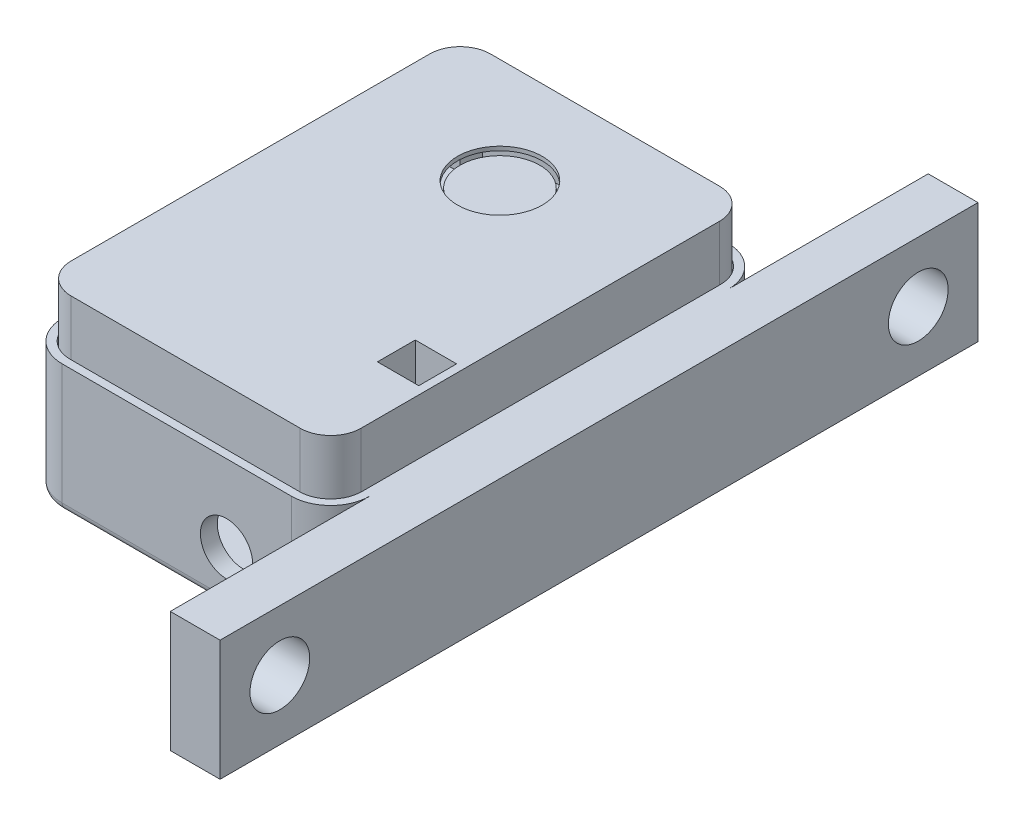
from build123d import *

# Parameters (mm, degrees)
BOSS_EXTRUDE1_DEPTH     = 1
SKETCH2_W               = 15
SKETCH2_H               = 15
BOSS_EXTRUDE2_DEPTH     = 2
SKETCH3_R               = 4
BOSS_EXTRUDE3_DEPTH     = 6.25
SKETCH5_W               = 3
SKETCH5_H               = 3
BOSS_EXTRUDE4_DEPTH     = 1
BOSS_EXTRUDE5_START     = 0.25
SKETCH6_R               = 4.25
BOSS_EXTRUDE5_DEPTH     = 0.4
BOSS_EXTRUDE7_DEPTH     = 9.5
BOSS_EXTRUDE9_DEPTH     = 8.4
SKETCH11_W              = 4.15
SKETCH11_H              = 3.8
CUT_EXTRUDE1_DEPTH      = 0.4
SKETCH12_W              = 18.75
SKETCH12_H              = 25.65
BOSS_EXTRUDE10_DEPTH    = 0.75
BOSS_EXTRUDE11_DEPTH    = 2.3
SKETCH14_W              = 2.5
SKETCH14_H              = 20.2
BOSS_EXTRUDE12_DEPTH    = 2.45
SKETCH16_W              = 0.6
SKETCH16_H              = 0.6
BOSS_EXTRUDE14_DEPTH    = 5.5
LPATTERN1_COUNT         = 8
LPATTERN1_PITCH         = 2.5
BOSS_EXTRUDE15_START    = 5
BOSS_EXTRUDE15_DEPTH    = 12.5
BOSS_EXTRUDE16_DEPTH    = 7.95
SKETCH19_W              = 3.5
SKETCH19_H              = 21.2
BOSS_EXTRUDE17_DEPTH    = 0.4
SKETCH20_R              = 2.625
CUT_EXTRUDE2_DEPTH      = 1.7
BOSS_EXTRUDE18_DEPTH    = 7.95
BOSS_EXTRUDE19_DEPTH    = 7.4
MIRROR1_COPY_1_SKETCH_W = 0.6
MIRROR1_COPY_1_SKETCH_H = 0.6
MIRROR1_COPY_1_DEPTH    = 5.5
MIRROR1_COPY_2_SKETCH_W = 0.6
MIRROR1_COPY_2_SKETCH_H = 0.6
MIRROR1_COPY_2_DEPTH    = 5.5
MIRROR1_COPY_3_SKETCH_W = 0.6
MIRROR1_COPY_3_SKETCH_H = 0.6
MIRROR1_COPY_3_DEPTH    = 5.5
MIRROR1_COPY_4_SKETCH_W = 0.6
MIRROR1_COPY_4_SKETCH_H = 0.6
MIRROR1_COPY_4_DEPTH    = 5.5
MIRROR1_COPY_5_SKETCH_W = 0.6
MIRROR1_COPY_5_SKETCH_H = 0.6
MIRROR1_COPY_5_DEPTH    = 5.5
MIRROR1_COPY_6_SKETCH_W = 0.6
MIRROR1_COPY_6_SKETCH_H = 0.6
MIRROR1_COPY_6_DEPTH    = 5.5
MIRROR1_COPY_7_SKETCH_W = 0.6
MIRROR1_COPY_7_SKETCH_H = 0.6
MIRROR1_COPY_7_DEPTH    = 5.5
FILLET2_R               = 0.8
SKETCH27_R              = 3
SKETCH27_W              = 36
SKETCH27_H              = 12.1
BOSS_EXTRUDE20_DEPTH    = 5


with BuildPart() as part:
    # Sketch1 → Boss-Extrude1 (new body)
    with BuildSketch(Plane(origin=(0, 0, 0), x_dir=(1, 0, 0), z_dir=(0, 1, 0))):
        with BuildLine():
            Line((-11.5, 20), (11.5, 20))
            ThreePointArc((11.5, 20), (12.914213562, 19.414213562), (13.5, 18))
            Line((13.5, 18), (13.5, -18))
            ThreePointArc((13.5, -18), (12.914213562, -19.414213562), (11.5, -20))
            Line((11.5, -20), (-11.5, -20))
            ThreePointArc((-11.5, -20), (-12.914213562, -19.414213562), (-13.5, -18))
            Line((-13.5, -18), (-13.5, 18))
            ThreePointArc((-13.5, 18), (-12.914213562, 19.414213562), (-11.5, 20))
        make_face()
    extrude(amount=BOSS_EXTRUDE1_DEPTH)

    # Sketch2 → Boss-Extrude2 (add)
    with BuildSketch(Plane(origin=(0, 1, 0), x_dir=(1, 0, 0), z_dir=(0, 1, 0))):
        with Locations((0, 12.5)):
            Rectangle(SKETCH2_W, SKETCH2_H)
    extrude(amount=BOSS_EXTRUDE2_DEPTH)

    # Sketch3 → Boss-Extrude3 (add)
    with BuildSketch(Plane(origin=(0, 3, 0), x_dir=(1, 0, 0), z_dir=(0, 1, 0))):
        with Locations((0, 10.5)):
            Circle(SKETCH3_R)
    extrude(amount=BOSS_EXTRUDE3_DEPTH)

    # Sketch5 → Boss-Extrude4 (add)
    with BuildSketch(Plane(origin=(0, 1, 0), x_dir=(1, 0, 0), z_dir=(0, 1, 0))):
        with Locations((11.5, -9.5)):
            Rectangle(SKETCH5_W, SKETCH5_H)
    extrude(amount=BOSS_EXTRUDE4_DEPTH)

    # Sketch12 → Boss-Extrude10 (add)
    with BuildSketch(Plane.XZ):
        with Locations((0, 7.175)):
            Rectangle(SKETCH12_W, SKETCH12_H)
    extrude(amount=BOSS_EXTRUDE10_DEPTH)

    # Sketch13 → Boss-Extrude11 (add)
    with BuildSketch(Plane.XZ.offset(0.75)):
        Polygon((2, 12.35), (-8, 12.35), (-8, -5.15), (8, -5.15), (8, 9.35), (2, 9.35), align=None)
    extrude(amount=BOSS_EXTRUDE11_DEPTH)

    # Sketch14 → Boss-Extrude12 (add)
    with BuildSketch(Plane.XZ):
        with Locations((11.5, -6.1)):
            Rectangle(SKETCH14_W, SKETCH14_H)
    boss_extrude12 = extrude(amount=BOSS_EXTRUDE12_DEPTH)

    # Sketch16 → Boss-Extrude14 (add)
    with BuildSketch(Plane.XZ.offset(2.45)):
        with Locations((11.5, 2.7)):
            Rectangle(SKETCH16_W, SKETCH16_H)
    boss_extrude14 = extrude(amount=BOSS_EXTRUDE14_DEPTH)

    # LPattern1: Boss-Extrude14 ×8
    with Locations(*[(0, 0, -i * LPATTERN1_PITCH) for i in range(1, LPATTERN1_COUNT)]):
        add(boss_extrude14)

    # Mirror1: Boss-Extrude12, Boss-Extrude14 across plane
    add(boss_extrude12.mirror(Plane(origin=(0, 0, 0), x_dir=(0, 0, 1), z_dir=(1, 0, 0))))
    add(boss_extrude14.mirror(Plane(origin=(0, 0, 0), x_dir=(0, 0, 1), z_dir=(1, 0, 0))))

    # Mirror1 copy 1 sketch → Mirror1 copy 1 (add)
    with BuildSketch(Plane(origin=(0, -2.45, -2.5), x_dir=(-1, 0, 0), z_dir=(0, -1, 0))):
        with Locations((11.5, -2.7)):
            Rectangle(MIRROR1_COPY_1_SKETCH_W, MIRROR1_COPY_1_SKETCH_H)
    extrude(amount=MIRROR1_COPY_1_DEPTH)

    # Mirror1 copy 2 sketch → Mirror1 copy 2 (add)
    with BuildSketch(Plane(origin=(0, -2.45, -5), x_dir=(-1, 0, 0), z_dir=(0, -1, 0))):
        with Locations((11.5, -2.7)):
            Rectangle(MIRROR1_COPY_2_SKETCH_W, MIRROR1_COPY_2_SKETCH_H)
    extrude(amount=MIRROR1_COPY_2_DEPTH)

    # Mirror1 copy 3 sketch → Mirror1 copy 3 (add)
    with BuildSketch(Plane(origin=(0, -2.45, -7.5), x_dir=(-1, 0, 0), z_dir=(0, -1, 0))):
        with Locations((11.5, -2.7)):
            Rectangle(MIRROR1_COPY_3_SKETCH_W, MIRROR1_COPY_3_SKETCH_H)
    extrude(amount=MIRROR1_COPY_3_DEPTH)

    # Mirror1 copy 4 sketch → Mirror1 copy 4 (add)
    with BuildSketch(Plane(origin=(0, -2.45, -10), x_dir=(-1, 0, 0), z_dir=(0, -1, 0))):
        with Locations((11.5, -2.7)):
            Rectangle(MIRROR1_COPY_4_SKETCH_W, MIRROR1_COPY_4_SKETCH_H)
    extrude(amount=MIRROR1_COPY_4_DEPTH)

    # Mirror1 copy 5 sketch → Mirror1 copy 5 (add)
    with BuildSketch(Plane(origin=(0, -2.45, -12.5), x_dir=(-1, 0, 0), z_dir=(0, -1, 0))):
        with Locations((11.5, -2.7)):
            Rectangle(MIRROR1_COPY_5_SKETCH_W, MIRROR1_COPY_5_SKETCH_H)
    extrude(amount=MIRROR1_COPY_5_DEPTH)

    # Mirror1 copy 6 sketch → Mirror1 copy 6 (add)
    with BuildSketch(Plane(origin=(0, -2.45, -15), x_dir=(-1, 0, 0), z_dir=(0, -1, 0))):
        with Locations((11.5, -2.7)):
            Rectangle(MIRROR1_COPY_6_SKETCH_W, MIRROR1_COPY_6_SKETCH_H)
    extrude(amount=MIRROR1_COPY_6_DEPTH)

    # Mirror1 copy 7 sketch → Mirror1 copy 7 (add)
    with BuildSketch(Plane(origin=(0, -2.45, -17.5), x_dir=(-1, 0, 0), z_dir=(0, -1, 0))):
        with Locations((11.5, -2.7)):
            Rectangle(MIRROR1_COPY_7_SKETCH_W, MIRROR1_COPY_7_SKETCH_H)
    extrude(amount=MIRROR1_COPY_7_DEPTH)


with BuildPart() as body_2:
    # Sketch6 → Boss-Extrude5 (new body)
    with BuildSketch(Plane(origin=(0, 9.25, 0), x_dir=(1, 0, 0), z_dir=(0, 1, 0)).offset(BOSS_EXTRUDE5_START)):
        with BuildLine():
            Line((7.5, 21.05), (-7.5, 21.05))
            Line((-7.5, 21.05), (-11.5, 21.05))
            ThreePointArc((-11.5, 21.05), (-13.656675683, 20.156675683), (-14.55, 18))
            Line((-14.55, 18), (-14.55, -18))
            ThreePointArc((-14.55, -18), (-13.656675683, -20.156675683), (-11.5, -21.05))
            Line((-11.5, -21.05), (11.5, -21.05))
            ThreePointArc((11.5, -21.05), (13.656675683, -20.156675683), (14.55, -18))
            Line((14.55, -18), (14.55, 18))
            ThreePointArc((14.55, 18), (13.656675683, 20.156675683), (11.5, 21.05))
            Line((11.5, 21.05), (7.5, 21.05))
        make_face()
        with Locations((0, 10.5)):
            Circle(SKETCH6_R, mode=Mode.SUBTRACT)
    extrude(amount=BOSS_EXTRUDE5_DEPTH)

    # Sketch8 → Boss-Extrude7 (add)
    with BuildSketch(Plane.XZ.offset(-9.5)):
        with BuildLine():
            Line((-11.5, -21.05), (11.5, -21.05))
            ThreePointArc((11.5, -21.05), (13.656675683, -20.156675683), (14.55, -18))
            Line((14.55, -18), (14.55, 18))
            ThreePointArc((14.55, 18), (13.656675683, 20.156675683), (11.5, 21.05))
            Line((11.5, 21.05), (-11.5, 21.05))
            ThreePointArc((-11.5, 21.05), (-13.656675683, 20.156675683), (-14.55, 18))
            Line((-14.55, 18), (-14.55, -18))
            ThreePointArc((-14.55, -18), (-13.656675683, -20.156675683), (-11.5, -21.05))
        make_face()
        with BuildLine():
            Line((-11.5, -20.25), (11.5, -20.25))
            ThreePointArc((11.5, -20.25), (13.090990258, -19.590990258), (13.75, -18))
            Line((13.75, -18), (13.75, 18))
            ThreePointArc((13.75, 18), (13.090990258, 19.590990258), (11.5, 20.25))
            Line((11.5, 20.25), (-11.5, 20.25))
            ThreePointArc((-11.5, 20.25), (-13.090990258, 19.590990258), (-13.75, 18))
            Line((-13.75, 18), (-13.75, -18))
            ThreePointArc((-13.75, -18), (-13.090990258, -19.590990258), (-11.5, -20.25))
        make_face(mode=Mode.SUBTRACT)
    extrude(amount=BOSS_EXTRUDE7_DEPTH)

    # Sketch9 → Boss-Extrude9 (add)
    with BuildSketch(Plane.XZ.offset(-9.5)):
        with BuildLine():
            Line((13.75, 18), (11.5, 18))
            Line((11.5, 18), (11.5, 20.25))
            ThreePointArc((11.5, 20.25), (13.090990258, 19.590990258), (13.75, 18))
        make_face()
        with BuildLine():
            Line((11.5, -18), (11.5, -20.25))
            ThreePointArc((11.5, -20.25), (13.090990258, -19.590990258), (13.75, -18))
            Line((13.75, -18), (11.5, -18))
        make_face()
        with BuildLine():
            Line((-13.75, -18), (-11.5, -18))
            Line((-11.5, -18), (-11.5, -20.25))
            ThreePointArc((-11.5, -20.25), (-13.090990258, -19.590990258), (-13.75, -18))
        make_face()
        with BuildLine():
            Line((-11.5, 18), (-11.5, 20.25))
            ThreePointArc((-11.5, 20.25), (-13.090990258, 19.590990258), (-13.75, 18))
            Line((-13.75, 18), (-11.5, 18))
        make_face()
    extrude(amount=BOSS_EXTRUDE9_DEPTH)

    # Sketch11 → Cut-Extrude1 (cut)
    with BuildSketch(Plane(origin=(0, 9.9, 0), x_dir=(1, 0, 0), z_dir=(0, 1, 0))):
        with Locations((11.675, -9.5)):
            Rectangle(SKETCH11_W, SKETCH11_H)
    extrude(amount=-CUT_EXTRUDE1_DEPTH, mode=Mode.SUBTRACT)

    # Sketch23 → Boss-Extrude19 (add)
    with BuildSketch(Plane.XZ.offset(-9.5)):
        Polygon((9.6, 11.4), (13.75, 11.4), (13.75, 12.2), (8.8, 12.2), (8.8, 6.8), (13.75, 6.8), (13.75, 7.6), (9.6, 7.6), align=None)
    extrude(amount=BOSS_EXTRUDE19_DEPTH)


with BuildPart() as body_3:
    # Sketch17 → Boss-Extrude15 (new body)
    with BuildSketch(Plane.XZ.offset(3.05).offset(BOSS_EXTRUDE15_START)):
        with BuildLine():
            Line((-11.5, -21.95), (11.5, -21.95))
            ThreePointArc((11.5, -21.95), (14.293071786, -20.793071786), (15.45, -18))
            Line((15.45, -18), (15.45, 18))
            ThreePointArc((15.45, 18), (14.293071786, 20.793071786), (11.5, 21.95))
            Line((11.5, 21.95), (-11.5, 21.95))
            ThreePointArc((-11.5, 21.95), (-14.293071786, 20.793071786), (-15.45, 18))
            Line((-15.45, 18), (-15.45, -18))
            ThreePointArc((-15.45, -18), (-14.293071786, -20.793071786), (-11.5, -21.95))
        make_face()
        with BuildLine():
            Line((-11.5, -21.15), (11.5, -21.15))
            ThreePointArc((11.5, -21.15), (13.727386361, -20.227386361), (14.65, -18))
            Line((14.65, -18), (14.65, 18))
            ThreePointArc((14.65, 18), (13.727386361, 20.227386361), (11.5, 21.15))
            Line((11.5, 21.15), (-11.5, 21.15))
            ThreePointArc((-11.5, 21.15), (-13.727386361, 20.227386361), (-14.65, 18))
            Line((-14.65, 18), (-14.65, -18))
            ThreePointArc((-14.65, -18), (-13.727386361, -20.227386361), (-11.5, -21.15))
        make_face(mode=Mode.SUBTRACT)
    extrude(amount=-BOSS_EXTRUDE15_DEPTH)

    # Sketch18 → Boss-Extrude16 (add)
    with BuildSketch(Plane.XZ.offset(8.05)):
        with BuildLine():
            Line((-11.5, -21.15), (11.5, -21.15))
            ThreePointArc((11.5, -21.15), (13.727386361, -20.227386361), (14.65, -18))
            Line((14.65, -18), (14.65, 18))
            ThreePointArc((14.65, 18), (13.727386361, 20.227386361), (11.5, 21.15))
            Line((11.5, 21.15), (-11.5, 21.15))
            ThreePointArc((-11.5, 21.15), (-13.727386361, 20.227386361), (-14.65, 18))
            Line((-14.65, 18), (-14.65, -18))
            ThreePointArc((-14.65, -18), (-13.727386361, -20.227386361), (-11.5, -21.15))
        make_face()
        with BuildLine():
            Line((-11.5, -20.25), (11.5, -20.25))
            ThreePointArc((11.5, -20.25), (13.090990258, -19.590990258), (13.75, -18))
            Line((13.75, -18), (13.75, 18))
            ThreePointArc((13.75, 18), (13.090990258, 19.590990258), (11.5, 20.25))
            Line((11.5, 20.25), (-11.5, 20.25))
            ThreePointArc((-11.5, 20.25), (-13.090990258, 19.590990258), (-13.75, 18))
            Line((-13.75, 18), (-13.75, -18))
            ThreePointArc((-13.75, -18), (-13.090990258, -19.590990258), (-11.5, -20.25))
        make_face(mode=Mode.SUBTRACT)
    extrude(amount=-BOSS_EXTRUDE16_DEPTH)

    # Sketch19 → Boss-Extrude17 (add)
    with BuildSketch(Plane.XZ.offset(8.05)):
        with BuildLine():
            Line((11.5, 21.95), (-11.5, 21.95))
            ThreePointArc((-11.5, 21.95), (-14.293071786, 20.793071786), (-15.45, 18))
            Line((-15.45, 18), (-15.45, -18))
            ThreePointArc((-15.45, -18), (-14.293071786, -20.793071786), (-11.5, -21.95))
            Line((-11.5, -21.95), (11.5, -21.95))
            ThreePointArc((11.5, -21.95), (14.293071786, -20.793071786), (15.45, -18))
            Line((15.45, -18), (15.45, 18))
            ThreePointArc((15.45, 18), (14.293071786, 20.793071786), (11.5, 21.95))
        make_face()
        with Locations((-11.5, -6.1)):
            Rectangle(SKETCH19_W, SKETCH19_H, mode=Mode.SUBTRACT)
        with Locations((11.5, -6.1)):
            Rectangle(SKETCH19_W, SKETCH19_H, mode=Mode.SUBTRACT)
    extrude(amount=BOSS_EXTRUDE17_DEPTH)

    # Sketch20 → Cut-Extrude2 (cut)
    with BuildSketch(Plane.XY.offset(21.95)):
        with Locations((5, -3.375)):
            Circle(SKETCH20_R)
    extrude(amount=-CUT_EXTRUDE2_DEPTH, mode=Mode.SUBTRACT)

    # Sketch22 → Boss-Extrude18 (add)
    with BuildSketch(Plane(origin=(0, -8.05, 0), x_dir=(1, 0, 0), z_dir=(0, 1, 0))):
        with BuildLine():
            Line((13.75, -18), (11.5, -18))
            Line((11.5, -18), (11.5, -20.25))
            ThreePointArc((11.5, -20.25), (13.090990258, -19.590990258), (13.75, -18))
        make_face()
        with BuildLine():
            Line((11.5, 18), (11.5, 20.25))
            ThreePointArc((11.5, 20.25), (13.090990258, 19.590990258), (13.75, 18))
            Line((13.75, 18), (11.5, 18))
        make_face()
        with BuildLine():
            Line((-13.75, 18), (-11.5, 18))
            Line((-11.5, 18), (-11.5, 20.25))
            ThreePointArc((-11.5, 20.25), (-13.090990258, 19.590990258), (-13.75, 18))
        make_face()
        with BuildLine():
            Line((-11.5, -18), (-11.5, -20.25))
            ThreePointArc((-11.5, -20.25), (-13.090990258, -19.590990258), (-13.75, -18))
            Line((-13.75, -18), (-11.5, -18))
        make_face()
    extrude(amount=BOSS_EXTRUDE18_DEPTH)

    # Fillet2
    fillet2_edges = [body_3.edges().sort_by_distance(p)[0] for p in [
        (14.293071786, -8.45, 20.793071786),
        (0, -8.45, 21.95),
        (-14.293071786, -8.45, 20.793071786),
        (-15.45, -8.45, 0),
        (-14.293071786, -8.45, -20.793071786),
        (0, -8.45, -21.95),
        (14.293071786, -8.45, -20.793071786),
        (15.45, -8.45, 0),
    ]]
    fillet(fillet2_edges, radius=FILLET2_R)

    # Sketch27 → Boss-Extrude20 (add)
    with BuildSketch(Plane(origin=(15.45, 0, 0), x_dir=(0, 0, -1), z_dir=(1, 0, 0))):
        Polygon((-18, -7.65), (-18, 4.45), (-38.05, 4.45), (-38.05, -7.65), (-21.95, -7.65), align=None)
        with Locations((-32.05, -1.6)):
            Circle(SKETCH27_R, mode=Mode.SUBTRACT)
        with Locations((0, -1.6)):
            Rectangle(SKETCH27_W, SKETCH27_H)
        Polygon((38.05, 4.45), (21.95, 4.45), (18, 4.45), (18, -7.65), (38.05, -7.65), align=None)
        with Locations((32.05, -1.6)):
            Circle(SKETCH27_R, mode=Mode.SUBTRACT)
    extrude(amount=BOSS_EXTRUDE20_DEPTH)


solid = Compound([part.part, body_2.part, body_3.part])
